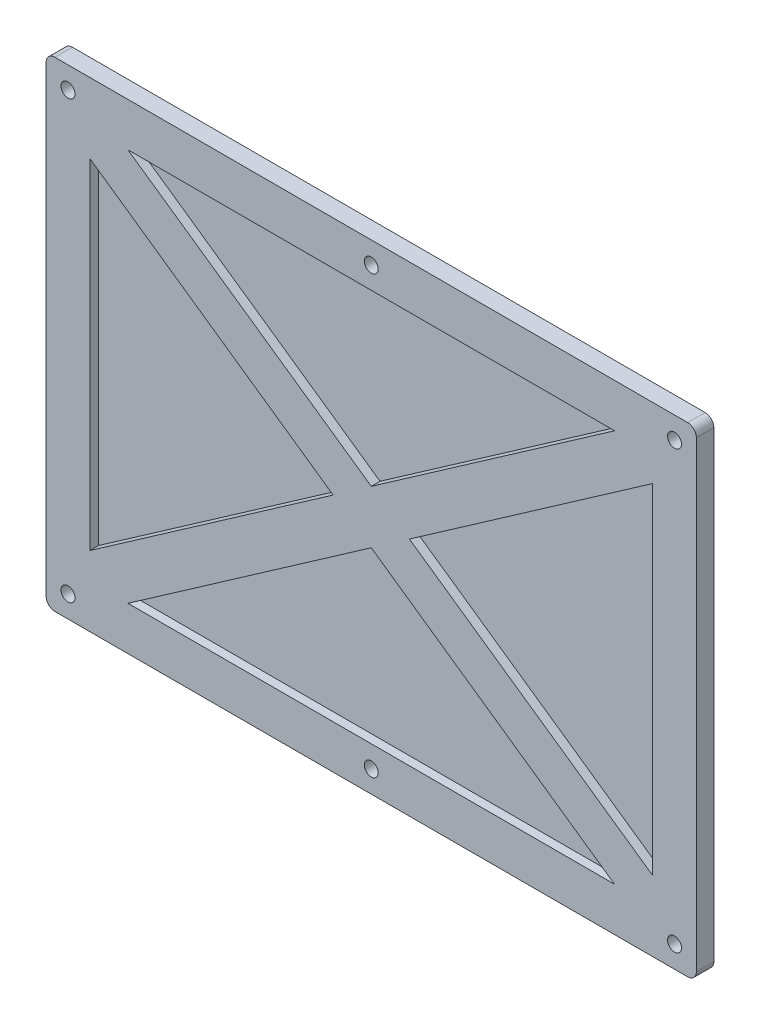
from build123d import *

# Parameters (mm, degrees)
SKICA1_W                = 149
SKICA1_H                = 110
SKICA1_R                = 1.6
P_IDAT_VYSUNUT_M1_DEPTH = 2
SKICA2_W                = 149
SKICA2_H                = 110
SKICA2_R                = 1.6
P_IDAT_VYSUNUT_M2_DEPTH = 2
ZAOBLIT1_R              = 2


with BuildPart() as part:
    # Skica1 → Přidat vysunutím1 (new body)
    with BuildSketch(Plane.XY):
        Rectangle(SKICA1_W, SKICA1_H)
        with Locations((-69.5, 50)):
            Circle(SKICA1_R, mode=Mode.SUBTRACT)
        with Locations((69.5, 50)):
            Circle(SKICA1_R, mode=Mode.SUBTRACT)
        with Locations((69.5, -50)):
            Circle(SKICA1_R, mode=Mode.SUBTRACT)
        with Locations((-69.5, -50)):
            Circle(SKICA1_R, mode=Mode.SUBTRACT)
        with Locations((0, 50)):
            Circle(SKICA1_R, mode=Mode.SUBTRACT)
        with Locations((0, -50)):
            Circle(SKICA1_R, mode=Mode.SUBTRACT)
    extrude(amount=P_IDAT_VYSUNUT_M1_DEPTH)

    # Skica2 → Přidat vysunutím2 (add)
    with BuildSketch(Plane.XY.offset(2)):
        Rectangle(SKICA2_W, SKICA2_H)
        with Locations((-69.5, -50)):
            Circle(SKICA2_R, mode=Mode.SUBTRACT)
        with Locations((69.5, -50)):
            Circle(SKICA2_R, mode=Mode.SUBTRACT)
        with Locations((69.5, 50)):
            Circle(SKICA2_R, mode=Mode.SUBTRACT)
        with Locations((-69.5, 50)):
            Circle(SKICA2_R, mode=Mode.SUBTRACT)
        with Locations((0, -50)):
            Circle(SKICA2_R, mode=Mode.SUBTRACT)
        with Locations((0, 50)):
            Circle(SKICA2_R, mode=Mode.SUBTRACT)
        Polygon((55.761515514, -45), (-55.761515514, -45), (0, -6.096617083), align=None, mode=Mode.SUBTRACT)
        Polygon((64.5, -38.903382917), (64.5, 38.903382917), (8.738484486, 0), align=None, mode=Mode.SUBTRACT)
        Polygon((55.761515514, 45), (-55.761515514, 45), (0, 6.096617083), align=None, mode=Mode.SUBTRACT)
        Polygon((-64.5, -38.903382917), (-64.5, 38.903382917), (-8.738484486, 0), align=None, mode=Mode.SUBTRACT)
    extrude(amount=P_IDAT_VYSUNUT_M2_DEPTH)

    # Zaoblit1
    zaoblit1_edges = [part.edges().sort_by_distance(p)[0] for p in [
        (74.5, -55, 2),
        (-74.5, -55, 2),
        (-74.5, 55, 2),
        (74.5, 55, 2),
    ]]
    fillet(zaoblit1_edges, radius=ZAOBLIT1_R)


solid = part.part
